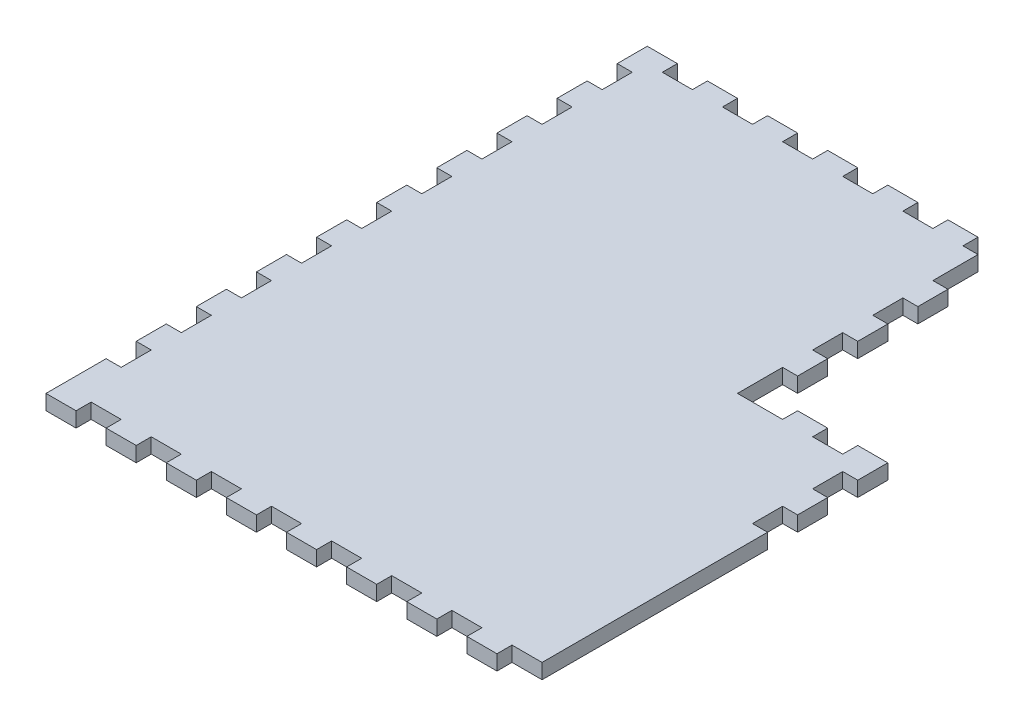
from build123d import *

# Parameters (mm, degrees)
SKETCH1_W           = 203.2
SKETCH1_H           = 254
BOSS_EXTRUDE1_DEPTH = 6.35
SKETCH2_W           = 50.8
SKETCH2_H           = 101.6
CUT_EXTRUDE2_DEPTH  = 7.35
SKETCH3_W           = 12.7
SKETCH3_H           = 6.35
CUT_EXTRUDE3_DEPTH  = 7.35
LPATTERN1_COUNT     = 8
LPATTERN1_PITCH     = 25.4
SKETCH4_W           = 6.35
SKETCH4_H           = 12.7
CUT_EXTRUDE4_DEPTH  = 7.35
LPATTERN2_COUNT     = 9
LPATTERN2_PITCH     = 25.4
SKETCH5_W           = 12.7
SKETCH5_H           = 6.35
CUT_EXTRUDE5_DEPTH  = 7.35
LPATTERN3_COUNT     = 6
LPATTERN3_PITCH     = 25.4
SKETCH7_W           = 6.35
SKETCH7_H           = 12.7
CUT_EXTRUDE8_DEPTH  = 7.35
LPATTERN5_COUNT     = 2
LPATTERN5_PITCH     = 25.4
SKETCH8_W           = 12.7
SKETCH8_H           = 6.35
CUT_EXTRUDE9_DEPTH  = 7.35
LPATTERN6_COUNT     = 2
LPATTERN6_PITCH     = 25.4
SKETCH9_W           = 6.35
SKETCH9_H           = 19.05
CUT_EXTRUDE10_DEPTH = 7.35
SKETCH10_W          = 6.35
SKETCH10_H          = 12.7
CUT_EXTRUDE11_DEPTH = 7.35
LPATTERN7_COUNT     = 3
LPATTERN7_PITCH     = 25.4
SKETCH11_W          = 6.35
SKETCH11_H          = 6.35
CUT_EXTRUDE12_DEPTH = 7.35


with BuildPart() as part:
    # Sketch1 → Boss-Extrude1 (new body)
    with BuildSketch(Plane(origin=(0, 0, 0), x_dir=(1, 0, 0), z_dir=(0, 1, 0))):
        Rectangle(SKETCH1_W, SKETCH1_H)
    extrude(amount=BOSS_EXTRUDE1_DEPTH)

    # Sketch2 → Cut-Extrude2 (cut, through all)
    with BuildSketch(Plane(origin=(0, 6.35, 0), x_dir=(1, 0, 0), z_dir=(0, 1, 0))):
        with Locations((76.2, 76.2)):
            Rectangle(SKETCH2_W, SKETCH2_H)
    extrude(amount=-CUT_EXTRUDE2_DEPTH, mode=Mode.SUBTRACT)

    # Sketch3 → Cut-Extrude3 (cut, through all)
    with BuildSketch(Plane(origin=(0, 6.35, 0), x_dir=(1, 0, 0), z_dir=(0, 1, 0))):
        with Locations((95.25, -123.825)):
            Rectangle(SKETCH3_W, SKETCH3_H)
    cut_extrude3 = extrude(amount=-CUT_EXTRUDE3_DEPTH, mode=Mode.SUBTRACT)

    # LPattern1: Cut-Extrude3 ×8
    with Locations(*[(-i * LPATTERN1_PITCH, 0, 0) for i in range(1, LPATTERN1_COUNT)]):
        add(cut_extrude3, mode=Mode.SUBTRACT)

    # Sketch4 → Cut-Extrude4 (cut, through all)
    with BuildSketch(Plane(origin=(0, 6.35, 0), x_dir=(1, 0, 0), z_dir=(0, 1, 0))):
        with Locations((-98.425, -95.25)):
            Rectangle(SKETCH4_W, SKETCH4_H)
    cut_extrude4 = extrude(amount=-CUT_EXTRUDE4_DEPTH, mode=Mode.SUBTRACT)

    # LPattern2: Cut-Extrude4 ×9
    with Locations(*[(0, 0, -i * LPATTERN2_PITCH) for i in range(1, LPATTERN2_COUNT)]):
        add(cut_extrude4, mode=Mode.SUBTRACT)

    # Sketch5 → Cut-Extrude5 (cut, through all)
    with BuildSketch(Plane(origin=(0, 6.35, 0), x_dir=(1, 0, 0), z_dir=(0, 1, 0))):
        with Locations((44.45, 123.825)):
            Rectangle(SKETCH5_W, SKETCH5_H)
    cut_extrude5 = extrude(amount=-CUT_EXTRUDE5_DEPTH, mode=Mode.SUBTRACT)

    # LPattern3: Cut-Extrude5 ×6
    with Locations(*[(-i * LPATTERN3_PITCH, 0, 0) for i in range(1, LPATTERN3_COUNT)]):
        add(cut_extrude5, mode=Mode.SUBTRACT)

    # Sketch7 → Cut-Extrude8 (cut, through all)
    with BuildSketch(Plane(origin=(0, 6.35, 0), x_dir=(1, 0, 0), z_dir=(0, 1, 0))):
        with Locations((98.425, 6.35)):
            Rectangle(SKETCH7_W, SKETCH7_H)
    cut_extrude8 = extrude(amount=-CUT_EXTRUDE8_DEPTH, mode=Mode.SUBTRACT)

    # LPattern5: Cut-Extrude8 ×2
    with Locations(*[(0, 0, i * LPATTERN5_PITCH) for i in range(1, LPATTERN5_COUNT)]):
        add(cut_extrude8, mode=Mode.SUBTRACT)

    # Sketch8 → Cut-Extrude9 (cut, through all)
    with BuildSketch(Plane(origin=(0, 6.35, 0), x_dir=(1, 0, 0), z_dir=(0, 1, 0))):
        with Locations((82.55, 22.225)):
            Rectangle(SKETCH8_W, SKETCH8_H)
    cut_extrude9 = extrude(amount=-CUT_EXTRUDE9_DEPTH, mode=Mode.SUBTRACT)

    # LPattern6: Cut-Extrude9 ×2
    with Locations(*[(-i * LPATTERN6_PITCH, 0, 0) for i in range(1, LPATTERN6_COUNT)]):
        add(cut_extrude9, mode=Mode.SUBTRACT)

    # Sketch9 → Cut-Extrude10 (cut, through all)
    with BuildSketch(Plane(origin=(0, 6.35, 0), x_dir=(1, 0, 0), z_dir=(0, 1, 0))):
        with Locations((47.625, 111.125)):
            Rectangle(SKETCH9_W, SKETCH9_H)
    extrude(amount=-CUT_EXTRUDE10_DEPTH, mode=Mode.SUBTRACT)

    # Sketch10 → Cut-Extrude11 (cut, through all)
    with BuildSketch(Plane(origin=(0, 6.35, 0), x_dir=(1, 0, 0), z_dir=(0, 1, 0))):
        with Locations((47.625, 82.55)):
            Rectangle(SKETCH10_W, SKETCH10_H)
    cut_extrude11 = extrude(amount=-CUT_EXTRUDE11_DEPTH, mode=Mode.SUBTRACT)

    # LPattern7: Cut-Extrude11 ×3
    with Locations(*[(0, 0, i * LPATTERN7_PITCH) for i in range(1, LPATTERN7_COUNT)]):
        add(cut_extrude11, mode=Mode.SUBTRACT)

    # Sketch11 → Cut-Extrude12 (cut, through all)
    with BuildSketch(Plane(origin=(0, 6.35, 0), x_dir=(1, 0, 0), z_dir=(0, 1, 0))):
        with Locations((47.625, 22.225)):
            Rectangle(SKETCH11_W, SKETCH11_H)
    extrude(amount=-CUT_EXTRUDE12_DEPTH, mode=Mode.SUBTRACT)


solid = part.part
